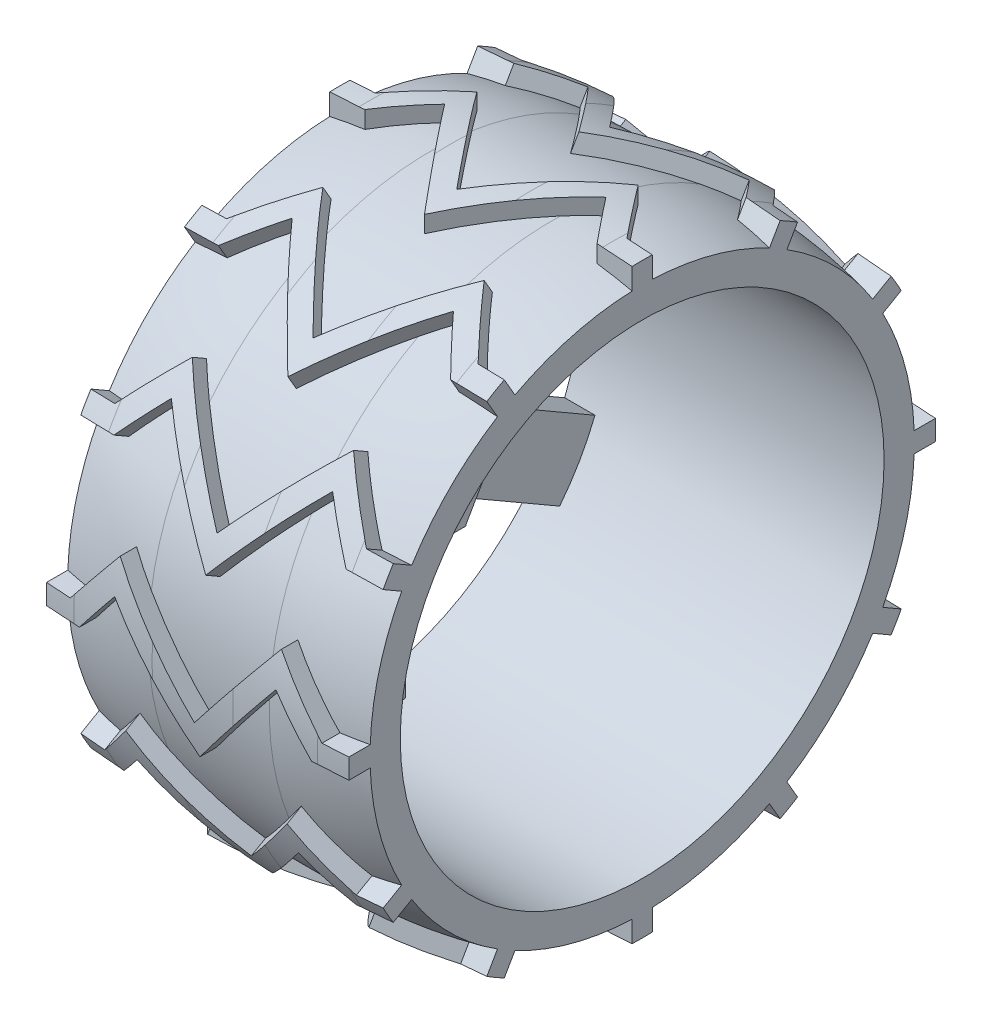
from build123d import *
from build123d.topology import SkipClean

# Parameters (mm, degrees)
VYSUNOUT_TENKOST_NN_1_DEPTH = 10
KRUHOV_POLE1_COUNT          = 12
SKICA4_R                    = 24
ODEBRAT_VYSUNUT_M2_DEPTH    = 15
SKICA5_R                    = 40
SKICA5_R_2                  = 30
ODEBRAT_VYSUNUT_M3_DEPTH    = 15
P_IDAT_VYSUNUT_M1_DEPTH     = 3.5
KRUHOV_POLE2_COUNT          = 6
SKICA9_R                    = 3.25
ODEBRAT_VYSUNUT_M4_DEPTH    = 4
SKICA10_R                   = 1.4
ODEBRAT_VYSUNUT_M5_DEPTH    = 12
SKICA13_R                   = 3.25
ODEBRAT_VYSUNUT_M7_DEPTH    = 2


with BuildPart() as part:
    # Skica1 → Rotovat1 (revolve)
    with BuildSketch(Plane.XY, mode=Mode.PRIVATE) as rotovat1_sk:
        with BuildLine():
            Line((15, 24), (-15, 24))
            Line((-15, 24), (-15, 27))
            ThreePointArc((-15, 27), (-10.527692569, 27.749233122), (-6, 28))
            Line((-6, 28), (6, 28))
            ThreePointArc((6, 28), (10.527692569, 27.749233122), (15, 27))
            Line((15, 27), (15, 24))
        make_face()
    revolve(rotovat1_sk.sketch.rotate(Axis((0, 0, 0), (-1, 0, 0)), 90), axis=Axis((0, 0, 0), (-1, 0, 0)))

    # Skica3 → Vysunout tenkostěnný1 (add)
    with BuildSketch(Plane(origin=(0, 30, 0), x_dir=(1, 0, 0), z_dir=(0, 1, 0))):
        Polygon((-15, -1), (-11.519375153, -1), (-8, 3.399218941), (-4.780868809, -0.624695048), (0, -6.600781059), (4.780868809, -0.624695048), (8, 3.399218941), (11.519375153, -1), (15, -1), (15, 1), (12.480624847, 1), (8, 6.600781059), (3.219131191, 0.624695048), (0, -3.399218941), (-3.219131191, 0.624695048), (-8, 6.600781059), (-12.480624847, 1), (-15, 1), align=None)
    vysunout_tenkost_nn_1 = extrude(amount=-VYSUNOUT_TENKOST_NN_1_DEPTH)

    # Kruhové pole1: Vysunout tenkostěnný1 ×12 about axis
    kruhov_pole1_axis = Axis((0, 0, 0), (1, 0, 0))
    for i in range(1, KRUHOV_POLE1_COUNT):
        add(vysunout_tenkost_nn_1.rotate(kruhov_pole1_axis, i * 360 / KRUHOV_POLE1_COUNT))

    # Skica4 → Odebrat vysunutím2 (cut, symmetric)
    with SkipClean():  # the faces are left unmerged after this step: merging them gives an invalid solid
        with BuildSketch(Plane(origin=(0, 0, 0), x_dir=(0, 0, -1), z_dir=(1, 0, 0))):
            Circle(SKICA4_R)
        extrude(amount=ODEBRAT_VYSUNUT_M2_DEPTH, both=True, mode=Mode.SUBTRACT)

    # Skica5 → Odebrat vysunutím3 (cut, symmetric)
    with SkipClean():  # the faces are left unmerged after this step: merging them gives an invalid solid
        with BuildSketch(Plane(origin=(0, 0, 0), x_dir=(0, 0, -1), z_dir=(1, 0, 0))):
            Circle(SKICA5_R)
            Circle(SKICA5_R_2, mode=Mode.SUBTRACT)
        extrude(amount=ODEBRAT_VYSUNUT_M3_DEPTH, both=True, mode=Mode.SUBTRACT)

    # Skica6 → Odebrat rotací1 (revolve, cut)
    with SkipClean():  # the faces are left unmerged after this step: merging them gives an invalid solid
        with BuildSketch(Plane.XY, mode=Mode.PRIVATE) as odebrat_rotac_1_sk:
            with BuildLine():
                ThreePointArc((-12.079800499, 29.295090248), (-13.540558014, 29.214595809), (-15, 29.11300366))
                Line((-15, 29.11300366), (-18.08905935, 33.832504157))
                Line((-18.08905935, 33.832504157), (1.013310959, 32.617757055))
                Line((1.013310959, 32.617757055), (17.108636414, 33.582209431))
                Line((17.108636414, 33.582209431), (15, 29.11300366))
                ThreePointArc((15, 29.11300366), (13.540558014, 29.214595809), (12.079800499, 29.295090248))
                ThreePointArc((12.079800499, 29.295090248), (8.043125064, 29.537233749), (4, 29.617991191))
                Line((4, 29.617991191), (-2, 29.617991191))
                Line((-2, 29.617991191), (-4, 29.617991191))
                ThreePointArc((-4, 29.617991191), (-8.043125064, 29.537233749), (-12.079800499, 29.295090248))
            make_face()
        revolve(odebrat_rotac_1_sk.sketch.rotate(Axis((0, 0, 0), (-1, 0, 0)), 90), axis=Axis((0, 0, 0), (-1, 0, 0)), mode=Mode.SUBTRACT)

    # Skica7 → Přidat vysunutím1 (add, symmetric)
    with SkipClean():  # the faces are left unmerged after this step: merging them gives an invalid solid
        with BuildSketch(Plane.XY):
            Polygon((-15, 24), (-15, 13), (-15, 0), (-6, 0), (-6, 5.965402213), (-12, 11), (-12, 24), align=None)
        p_idat_vysunut_m1 = extrude(amount=P_IDAT_VYSUNUT_M1_DEPTH, both=True)

    # Kruhové pole2: Přidat vysunutím1 ×6 about axis
    with SkipClean():  # the faces are left unmerged after this step: merging them gives an invalid solid
        kruhov_pole2_axis = Axis((0, 0, 0), (1, 0, 0))
        for i in range(1, KRUHOV_POLE2_COUNT):
            add(p_idat_vysunut_m1.rotate(kruhov_pole2_axis, i * 360 / KRUHOV_POLE2_COUNT))

    # Skica9 → Odebrat vysunutím4 (cut)
    with SkipClean():  # the faces are left unmerged after this step: merging them gives an invalid solid
        with BuildSketch(Plane.ZY.offset(15)):
            with Locations(Location((0, 0, 0), (0, 0, 270))):
                Circle(SKICA9_R)
        extrude(amount=-ODEBRAT_VYSUNUT_M4_DEPTH, mode=Mode.SUBTRACT)

    # Skica10 → Odebrat vysunutím5 (cut)
    with SkipClean():  # the faces are left unmerged after this step: merging them gives an invalid solid
        with BuildSketch(Plane.ZY.offset(11)):
            with Locations(Location((0, 0, 0), (0, 0, 270))):
                Circle(SKICA10_R)
        extrude(amount=-ODEBRAT_VYSUNUT_M5_DEPTH, mode=Mode.SUBTRACT)

    # Skica13 → Odebrat vysunutím7 (cut)
    with SkipClean():  # the faces are left unmerged after this step: merging them gives an invalid solid
        with BuildSketch(Plane(origin=(-6, 0, 0), x_dir=(0, 0, -1), z_dir=(1, 0, 0))):
            with Locations(Location((0, 0, 0), (0, 0, 270))):
                Circle(SKICA13_R)
        extrude(amount=-ODEBRAT_VYSUNUT_M7_DEPTH, mode=Mode.SUBTRACT)


solid = part.part
